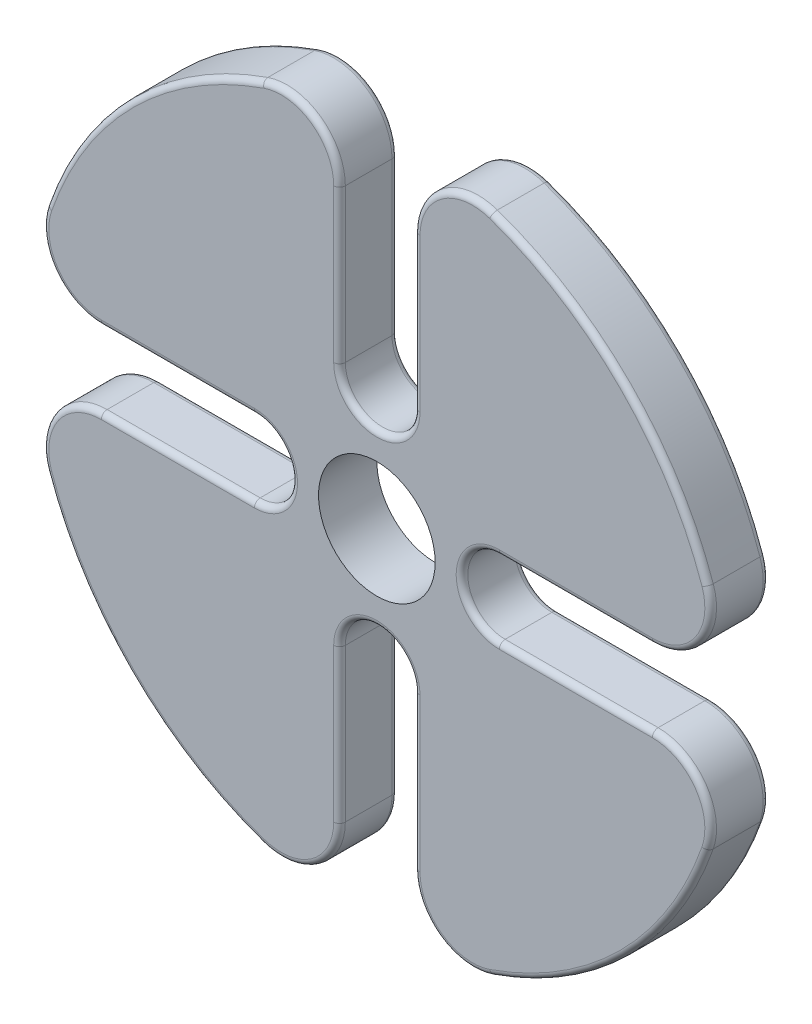
from build123d import *

# Parameters (mm, degrees)
SKICA1_R                = 5
P_IDAT_VYSUNUT_M1_DEPTH = 5
ZAOBLIT1_R              = 5
ZAOBLIT2_R              = 0.5


with BuildPart() as part:
    # Skica1 → Přidat vysunutím1 (new body)
    with BuildSketch(Plane.XY):
        with BuildLine():
            Line((-3.2, 29.8288451), (-3.2, 10.5))
            ThreePointArc((-3.2, 10.5), (0, 7.3), (3.2, 10.5))
            Line((3.2, 10.5), (3.2, 29.8288451))
            ThreePointArc((3.2, 29.8288451), (21.213203436, 21.213203436), (29.8288451, 3.2))
            Line((29.8288451, 3.2), (10.5, 3.2))
            ThreePointArc((10.5, 3.2), (7.3, 0), (10.5, -3.2))
            Line((10.5, -3.2), (29.8288451, -3.2))
            ThreePointArc((29.8288451, -3.2), (21.213203436, -21.213203436), (3.2, -29.8288451))
            Line((3.2, -29.8288451), (3.2, -10.5))
            ThreePointArc((3.2, -10.5), (0, -7.3), (-3.2, -10.5))
            Line((-3.2, -10.5), (-3.2, -29.8288451))
            ThreePointArc((-3.2, -29.8288451), (-21.213203436, -21.213203436), (-29.8288451, -3.2))
            Line((-29.8288451, -3.2), (-10.5, -3.2))
            ThreePointArc((-10.5, -3.2), (-7.3, 0), (-10.5, 3.2))
            Line((-10.5, 3.2), (-29.8288451, 3.2))
            ThreePointArc((-29.8288451, 3.2), (-21.213203436, 21.213203436), (-3.2, 29.8288451))
        make_face()
        Circle(SKICA1_R, mode=Mode.SUBTRACT)
    extrude(amount=P_IDAT_VYSUNUT_M1_DEPTH)

    # Zaoblit1
    zaoblit1_edges = [part.edges().sort_by_distance(p)[0] for p in [
        (-3.2, 29.8288451, 2.5),
        (3.2, 29.8288451, 2.5),
        (29.8288451, 3.2, 2.5),
        (29.8288451, -3.2, 2.5),
        (3.2, -29.8288451, 2.5),
        (-3.2, -29.8288451, 2.5),
        (-29.8288451, -3.2, 2.5),
        (-29.8288451, 3.2, 2.5),
    ]]
    fillet(zaoblit1_edges, radius=ZAOBLIT1_R)

    # Zaoblit2
    zaoblit2_edges = [part.edges().sort_by_distance(p)[0] for p in [
        (-7.3, 0, 5),
        (-17.058471535, -3.2, 5),
        (-3.2, 17.058471535, 0),
        (0, 7.3, 0),
        (17.058471535, 3.2, 0),
        (7.3, 0, 0),
        (3.2, -17.058471535, 0),
        (0, -7.3, 0),
        (-17.058471535, -3.2, 0),
        (-7.3, 0, 0),
        (0, -7.3, 5),
        (3.2, -17.058471535, 5),
        (7.3, 0, 5),
        (17.058471535, 3.2, 5),
        (0, 7.3, 5),
        (-21.213203436, 21.213203436, 0),
        (-21.213203436, 21.213203436, 5),
        (-3.2, 17.058471535, 5),
        (3.2, 17.058471535, 0),
        (21.213203436, 21.213203436, 0),
        (17.058471535, -3.2, 0),
        (21.213203436, -21.213203436, 0),
        (-3.2, -17.058471535, 0),
        (-21.213203436, -21.213203436, 0),
        (-17.058471535, 3.2, 0),
        (-27.691252828, 5.301724651, 0),
        (-27.691252828, -5.301724651, 0),
        (-5.301724651, -27.691252828, 0),
        (5.301724651, -27.691252828, 0),
        (27.691252828, -5.301724651, 0),
        (27.691252828, 5.301724651, 0),
        (5.301724651, 27.691252828, 0),
        (-5.301724651, 27.691252828, 0),
        (-17.058471535, 3.2, 5),
        (-21.213203436, -21.213203436, 5),
        (-3.2, -17.058471535, 5),
        (21.213203436, -21.213203436, 5),
        (17.058471535, -3.2, 5),
        (21.213203436, 21.213203436, 5),
        (3.2, 17.058471535, 5),
        (-27.691252828, 5.301724651, 5),
        (-27.691252828, -5.301724651, 5),
        (-5.301724651, -27.691252828, 5),
        (5.301724651, -27.691252828, 5),
        (27.691252828, -5.301724651, 5),
        (27.691252828, 5.301724651, 5),
        (5.301724651, 27.691252828, 5),
        (-5.301724651, 27.691252828, 5),
    ]]
    fillet(zaoblit2_edges, radius=ZAOBLIT2_R)


solid = part.part
